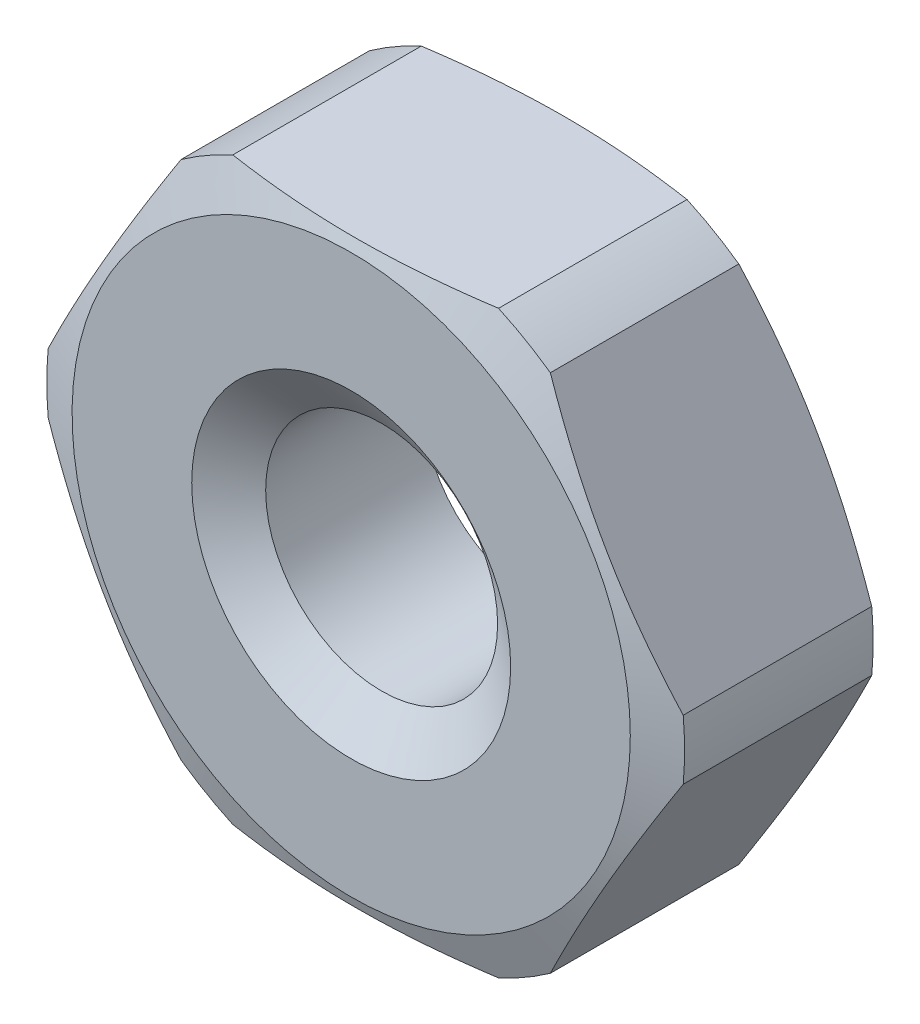
from build123d import *

# Parameters (mm, degrees)
SKETCH_1_R      = 0.8
EXTRUDE_1_DEPTH = 1.5


with BuildPart() as part:
    # Эскиз1 → Бобышка-Вытянуть1 (new body)
    with BuildSketch(Plane.XY):
        Polygon((2.309401077, 0), (1.154700538, 2), (-1.154700538, 2), (-2.309401077, 0), (-1.154700538, -2), (1.154700538, -2), align=None)
        Circle(SKETCH_1_R, mode=Mode.SUBTRACT)
    extrude(amount=EXTRUDE_1_DEPTH)

    # Эскиз2 → Вырез-Повернуть1 (revolve, cut)
    with BuildSketch(Plane(origin=(0, 0, 0), x_dir=(1, 0, 0), z_dir=(0, 1, 0))):
        Polygon((1.925252258, 0), (2.2, -0.1), (2.2, -1.4), (1.925252258, -1.5), (1.925252258, -1.776730112), (2.772458497, -1.776730112), (2.772458497, 0.295805662), (1.925252258, 0.295805662), align=None)
    revolve(axis=Axis((0, 0, 0), (0, 0, 1)), mode=Mode.SUBTRACT)

    # Эскиз3 → Отверстие обработанное метчиком M2x0.41 (revolve, cut)
    with BuildSketch(Plane.YZ):
        Polygon((0, 0), (0, 1.5), (1.1, 1.5), (0.8, 1.289937739), (0.8, 0.210062261), (1.1, 0), align=None)
    revolve(axis=Axis((0, 0, -6.35), (0, 0, 1)), mode=Mode.SUBTRACT)


solid = part.part
